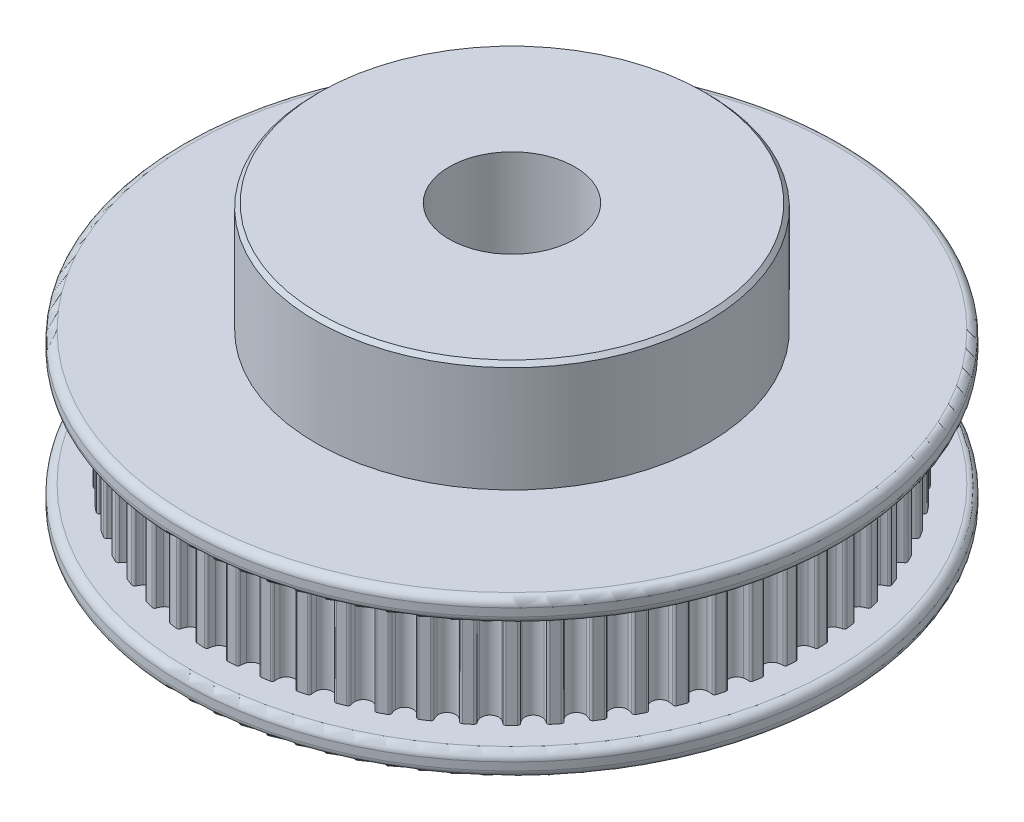
from build123d import *

# Parameters (mm, degrees)
CUT_EXTRUDE1_START = -1.5
SKETCH2_R          = 24.481100841
SKETCH2_R_2        = 4
CUT_EXTRUDE1_DEPTH = 7
FILLET1_R          = 0.5
CHAMFER1_SIZE      = 0.25


with BuildPart() as part:
    # Sketch1 → Revolve1 (revolve)
    with BuildSketch(Plane.XY):
        Polygon((4, 7.184233151), (4, 14.184233151), (12.5, 14.184233151), (12.5, 7.184233151), (21, 7.184233151), (21, -2.815766849), (4, -2.815766849), align=None)
    revolve(axis=Axis((0, -5.578947368, 0), (0, 1, 0)))

    # Sketch2 → Cut-Extrude1 (cut)
    with BuildSketch(Plane.XZ.offset(2.815766849).offset(CUT_EXTRUDE1_START)):
        with Locations((-0.003412539, -0.008889969)):
            Circle(SKETCH2_R)
        with BuildLine():
            ThreePointArc((18.830466584, -0.729534099), (18.793183335, -0.630564739), (18.699867462, -0.580794038))
            ThreePointArc((18.699867462, -0.580794038), (18.534343714, -0.551850804), (18.3760031, -0.495600717))
            ThreePointArc((18.3760031, -0.495600717), (18.152095447, -0.290974394), (18.069206646, 0.000806374))
            ThreePointArc((18.069206646, 0.000806374), (18.152095447, 0.292587141), (18.3760031, 0.497213465))
            ThreePointArc((18.3760031, 0.497213465), (18.534343714, 0.553463551), (18.699867462, 0.582406785))
            ThreePointArc((18.699867462, 0.582406785), (18.793183335, 0.632177487), (18.830466584, 0.731146846))
            ThreePointArc((18.830466584, 0.731146846), (18.818767311, 0.987862551), (18.803568396, 1.244394847))
            ThreePointArc((18.803568396, 1.244394847), (18.756144273, 1.338924881), (18.65813714, 1.378668769))
            ThreePointArc((18.65813714, 1.378668769), (18.490494756, 1.390151506), (18.327141814, 1.429542348))
            ThreePointArc((18.327141814, 1.429542348), (18.083071475, 1.609642984), (17.970137352, 1.891161107))
            ThreePointArc((17.970137352, 1.891161107), (18.022072685, 2.190007707), (18.223364473, 2.41691779))
            ThreePointArc((18.223364473, 2.41691779), (18.374957945, 2.489410833), (18.536549545, 2.535497456))
            ThreePointArc((18.536549545, 2.535497456), (18.624151769, 2.594749673), (18.650885662, 2.697074029))
            ThreePointArc((18.650885662, 2.697074029), (18.61241638, 2.951160511), (18.5704858, 3.204698777))
            ThreePointArc((18.5704858, 3.204698777), (18.513440392, 3.293753796), (18.411815784, 3.323035427))
            ThreePointArc((18.411815784, 3.323035427), (18.24389149, 3.31693186), (18.077315949, 3.339031882))
            ThreePointArc((18.077315949, 3.339031882), (17.81575701, 3.492633611), (17.674014895, 3.760804718))
            ThreePointArc((17.674014895, 3.760804718), (17.694427745, 4.063442926), (17.870898274, 4.310150692))
            ThreePointArc((17.870898274, 4.310150692), (18.014083714, 4.398092444), (18.169972734, 4.460817521))
            ThreePointArc((18.169972734, 4.460817521), (18.250901521, 4.528902074), (18.266793155, 4.63346034))
            ThreePointArc((18.266793155, 4.63346034), (18.201975343, 4.882133774), (18.133772497, 5.129900192))
            ThreePointArc((18.133772497, 5.129900192), (18.067730806, 5.212504489), (17.963602144, 5.231003049))
            ThreePointArc((17.963602144, 5.231003049), (17.797235754, 5.207380048), (17.629262649, 5.211947119))
            ThreePointArc((17.629262649, 5.211947119), (17.353080805, 5.337367048), (17.184083655, 5.589253))
            ThreePointArc((17.184083655, 5.589253), (17.172750374, 5.892367048), (17.322466195, 6.156169517))
            ThreePointArc((17.322466195, 6.156169517), (17.455674834, 6.258596468), (17.604153322, 6.337272771))
            ThreePointArc((17.604153322, 6.337272771), (17.677521998, 6.413443711), (17.682397262, 6.519090324))
            ThreePointArc((17.682397262, 6.519090324), (17.591941076, 6.759626193), (17.498213211, 6.998906182))
            ThreePointArc((17.498213211, 6.998906182), (17.423898802, 7.074154727), (17.318406942, 7.081667541))
            ThreePointArc((17.318406942, 7.081667541), (17.1554212, 7.040783927), (16.987890881, 7.027768008))
            ThreePointArc((16.987890881, 7.027768008), (16.700112037, 7.12363201), (16.50571142, 7.356473091))
            ThreePointArc((16.50571142, 7.356473091), (16.462756178, 7.656741999), (16.584076973, 7.934748895))
            ThreePointArc((16.584076973, 7.934748895), (16.70584935, 8.050538835), (16.845290544, 8.144304368))
            ThreePointArc((16.845290544, 8.144304368), (16.910295268, 8.227727152), (16.904100746, 8.333304625))
            ThreePointArc((16.904100746, 8.333304625), (16.788997244, 8.563067567), (16.67077126, 8.791239525))
            ThreePointArc((16.67077126, 8.791239525), (16.588998339, 8.85830788), (16.483299071, 8.854752636))
            ThreePointArc((16.483299071, 8.854752636), (16.325479684, 8.797056338), (16.160227647, 8.766600035))
            ThreePointArc((16.160227647, 8.766600035), (15.864004769, 8.831857803), (15.646330578, 9.043102959))
            ThreePointArc((15.646330578, 9.043102959), (15.572224002, 9.337236917), (15.663820556, 9.626402338))
            ThreePointArc((15.663820556, 9.626402338), (15.772822506, 9.754286648), (15.90169866, 9.862114098))
            ThreePointArc((15.90169866, 9.862114098), (15.957627226, 9.951874727), (15.940430787, 10.056226331))
            ThreePointArc((15.940430787, 10.056226331), (15.801941067, 10.272699016), (15.660512273, 10.487263044))
            ThreePointArc((15.660512273, 10.487263044), (15.57217676, 10.545416394), (15.467428149, 10.530832043))
            ThreePointArc((15.467428149, 10.530832043), (15.316504218, 10.456955193), (15.155340999, 10.409392192))
            ThreePointArc((15.155340999, 10.409392192), (14.853919567, 10.443328749), (14.615356687, 10.630663533))
            ThreePointArc((14.615356687, 10.630663533), (14.510910704, 10.915439948), (14.571779465, 11.212595737))
            ThreePointArc((14.571779465, 11.212595737), (14.666816741, 11.351173291), (14.78371586, 11.471881277))
            ThreePointArc((14.78371586, 11.471881277), (14.829955502, 11.566996314), (14.801945555, 11.668978752))
            ThreePointArc((14.801945555, 11.668978752), (14.641586939, 11.86978946), (14.478504858, 12.068394749))
            ThreePointArc((14.478504858, 12.068394749), (14.384574576, 12.116995953), (14.281924269, 12.091542286))
            ThreePointArc((14.281924269, 12.091542286), (14.139549348, 12.002294294), (13.984240686, 11.938145705))
            ThreePointArc((13.984240686, 11.938145705), (13.680923136, 11.940389234), (13.424085311, 12.101761168))
            ThreePointArc((13.424085311, 12.101761168), (13.290444253, 12.374059969), (13.319918331, 12.675950427))
            ThreePointArc((13.319918331, 12.675950427), (13.399949683, 12.823702938), (13.503590997, 12.955968958))
            ThreePointArc((13.503590997, 12.955968958), (13.539635105, 13.055396304), (13.501118531, 13.153892235))
            ThreePointArc((13.501118531, 13.153892235), (13.320647942, 13.336840841), (13.137699337, 13.51731143))
            ThreePointArc((13.137699337, 13.51731143), (13.039203406, 13.555828004), (12.939776059, 13.519783896))
            ThreePointArc((12.939776059, 13.519783896), (12.807510039, 13.416142582), (12.659757528, 13.336111229))
            ThreePointArc((12.659757528, 13.336111229), (12.35786707, 13.306637152), (12.085568269, 13.44027821))
            ThreePointArc((12.085568269, 13.44027821), (11.924196336, 13.697116035), (11.921952806, 14.000433585))
            ThreePointArc((11.921952806, 14.000433585), (11.986101396, 14.155742247), (12.075349387, 14.298117167))
            ThreePointArc((12.075349387, 14.298117167), (12.100803054, 14.400767475), (12.05220185, 14.494697757))
            ThreePointArc((12.05220185, 14.494697757), (11.853596561, 14.657779838), (11.652785854, 14.818138453))
            ThreePointArc((11.652785854, 14.818138453), (11.550803415, 14.846148401), (11.455688378, 14.799908759))
            ThreePointArc((11.455688378, 14.799908759), (11.334980392, 14.683009639), (11.196402839, 14.587972364))
            ThreePointArc((11.196402839, 14.587972364), (10.899247049, 14.527103602), (10.614470635, 14.631549585))
            ThreePointArc((10.614470635, 14.631549585), (10.42713585, 14.870112466), (10.393199293, 15.171533898))
            ThreePointArc((10.393199293, 15.171533898), (10.440762294, 15.332697116), (10.514639145, 15.483621048))
            ThreePointArc((10.514639145, 15.483621048), (10.529223495, 15.588369659), (10.471070145, 15.676705172))
            ThreePointArc((10.471070145, 15.676705172), (10.256506117, 15.818133966), (10.040033432, 15.956623686))
            ThreePointArc((10.040033432, 15.956623686), (9.935681828, 15.973820124), (9.845921199, 15.917891559))
            ThreePointArc((9.845921199, 15.917891559), (9.73809375, 15.789015405), (9.610209439, 15.680013455))
            ThreePointArc((9.610209439, 15.680013455), (9.321044018, 15.588416901), (9.02691006, 15.662523477))
            ThreePointArc((9.02691006, 15.662523477), (8.815664904, 15.880197668), (8.750407136, 16.176420546))
            ThreePointArc((8.750407136, 16.176420546), (8.780863439, 16.341672582), (8.838559737, 16.49949197))
            ThreePointArc((8.838559737, 16.49949197), (8.842114982, 16.605191238), (8.775046627, 16.686964159))
            ThreePointArc((8.775046627, 16.686964159), (8.546874669, 16.805190143), (8.317111726, 16.920293645))
            ThreePointArc((8.317111726, 16.920293645), (8.211534253, 16.926488167), (8.12811147, 16.861483443))
            ThreePointArc((8.12811147, 16.861483443), (8.034345936, 16.722042249), (7.918555996, 16.600269872))
            ThreePointArc((7.918555996, 16.600269872), (7.6405491, 16.478949077), (7.340280193, 16.521904318))
            ThreePointArc((7.340280193, 16.521904318), (7.107439111, 16.716304936), (7.01157511, 17.00408378))
            ThreePointArc((7.01157511, 17.00408378), (7.024591028, 17.171614099), (7.065474642, 17.334599841))
            ThreePointArc((7.065474642, 17.334599841), (7.057961828, 17.440091701), (6.982713283, 17.514406109))
            ThreePointArc((6.982713283, 17.514406109), (6.743433294, 17.608133975), (6.502897425, 17.698590161))
            ThreePointArc((6.502897425, 17.698590161), (6.397250813, 17.693714897), (6.321079872, 17.620346221))
            ThreePointArc((6.321079872, 17.620346221), (6.24240357, 17.471867733), (6.139976618, 17.338659093))
            ThreePointArc((6.139976618, 17.338659093), (5.876174149, 17.188943272), (5.573060101, 17.200276553))
            ThreePointArc((5.573060101, 17.200276553), (5.321174149, 17.369273704), (5.195754221, 17.645455548))
            ThreePointArc((5.195754221, 17.645455548), (5.19118715, 17.813428653), (5.21481015, 17.979795043))
            ThreePointArc((5.21481015, 17.979795043), (5.19631159, 18.083923705), (5.113707293, 18.149965396))
            ThreePointArc((5.113707293, 18.149965396), (4.865940876, 18.218168242), (4.617267441, 18.282986054))
            ThreePointArc((4.617267441, 18.282986054), (4.512709176, 18.26709442), (4.444624622, 18.186165633))
            ThreePointArc((4.444624622, 18.186165633), (4.381899545, 18.030276613), (4.293957793, 17.887091172))
            ThreePointArc((4.293957793, 17.887091172), (4.047250027, 17.710620644), (3.744611819, 17.690207794))
            ThreePointArc((3.744611819, 17.690207794), (3.476440712, 17.831949909), (3.322838983, 18.093508848))
            ThreePointArc((3.322838983, 18.093508848), (3.300738961, 18.260084389), (3.306842529, 18.428008683))
            ThreePointArc((3.306842529, 18.428008683), (3.277560897, 18.529633291), (3.188505878, 18.586678699))
            ThreePointArc((3.188505878, 18.586678699), (2.934967613, 18.628609279), (2.680881131, 18.66707856))
            ThreePointArc((2.680881131, 18.66707856), (2.578556775, 18.640344667), (2.519304557, 18.552742444))
            ThreePointArc((2.519304557, 18.552742444), (2.473217934, 18.391150844), (2.400724891, 18.239557372))
            ThreePointArc((2.400724891, 18.239557372), (2.173814809, 18.038265584), (1.874968208, 17.986330251))
            ThreePointArc((1.874968208, 17.986330251), (1.593450085, 18.099264374), (1.413349449, 18.343334713))
            ThreePointArc((1.413349449, 18.343334713), (1.373958607, 18.506687655), (1.362475871, 18.674330038))
            ThreePointArc((1.362475871, 18.674330038), (1.322731983, 18.772337172), (1.228201948, 18.819761295))
            ThreePointArc((1.228201948, 18.819761295), (0.971669652, 18.83496021), (0.714953948, 18.846659483))
            ThreePointArc((0.714953948, 18.846659483), (0.615984588, 18.809376233), (0.566213886, 18.716060361))
            ThreePointArc((0.566213886, 18.716060361), (0.537270652, 18.550536612), (0.481020566, 18.392195999))
            ThreePointArc((0.481020566, 18.392195999), (0.276394242, 18.168288346), (-0.015386525, 18.085399545))
            ThreePointArc((-0.015386525, 18.085399545), (-0.307167292, 18.168288346), (-0.511793616, 18.392195999))
            ThreePointArc((-0.511793616, 18.392195999), (-0.568043703, 18.550536612), (-0.596986936, 18.716060361))
            ThreePointArc((-0.596986936, 18.716060361), (-0.646757638, 18.809376233), (-0.745726998, 18.846659483))
            ThreePointArc((-0.745726998, 18.846659483), (-1.002442702, 18.83496021), (-1.258974998, 18.819761295))
            ThreePointArc((-1.258974998, 18.819761295), (-1.353505033, 18.772337172), (-1.393248921, 18.674330038))
            ThreePointArc((-1.393248921, 18.674330038), (-1.404731657, 18.506687655), (-1.444122499, 18.343334713))
            ThreePointArc((-1.444122499, 18.343334713), (-1.624223135, 18.099264374), (-1.905741258, 17.986330251))
            ThreePointArc((-1.905741258, 17.986330251), (-2.204587859, 18.038265584), (-2.431497941, 18.239557372))
            ThreePointArc((-2.431497941, 18.239557372), (-2.503990985, 18.391150844), (-2.550077607, 18.552742444))
            ThreePointArc((-2.550077607, 18.552742444), (-2.609329825, 18.640344667), (-2.711654181, 18.66707856))
            ThreePointArc((-2.711654181, 18.66707856), (-2.965740663, 18.628609279), (-3.219278929, 18.586678699))
            ThreePointArc((-3.219278929, 18.586678699), (-3.308333947, 18.529633291), (-3.337615579, 18.428008683))
            ThreePointArc((-3.337615579, 18.428008683), (-3.331512011, 18.260084389), (-3.353612034, 18.093508848))
            ThreePointArc((-3.353612034, 18.093508848), (-3.507213763, 17.831949909), (-3.775384869, 17.690207794))
            ThreePointArc((-3.775384869, 17.690207794), (-4.078023077, 17.710620644), (-4.324730844, 17.887091172))
            ThreePointArc((-4.324730844, 17.887091172), (-4.412672596, 18.030276613), (-4.475397672, 18.186165633))
            ThreePointArc((-4.475397672, 18.186165633), (-4.543482226, 18.26709442), (-4.648040491, 18.282986054))
            ThreePointArc((-4.648040491, 18.282986054), (-4.896713926, 18.218168242), (-5.144480344, 18.149965396))
            ThreePointArc((-5.144480344, 18.149965396), (-5.22708464, 18.083923705), (-5.2455832, 17.979795043))
            ThreePointArc((-5.2455832, 17.979795043), (-5.2219602, 17.813428653), (-5.226527271, 17.645455548))
            ThreePointArc((-5.226527271, 17.645455548), (-5.3519472, 17.369273704), (-5.603833151, 17.200276553))
            ThreePointArc((-5.603833151, 17.200276553), (-5.9069472, 17.188943272), (-6.170749668, 17.338659093))
            ThreePointArc((-6.170749668, 17.338659093), (-6.27317662, 17.471867733), (-6.351852922, 17.620346221))
            ThreePointArc((-6.351852922, 17.620346221), (-6.428023863, 17.693714897), (-6.533670475, 17.698590161))
            ThreePointArc((-6.533670475, 17.698590161), (-6.774206344, 17.608133975), (-7.013486333, 17.514406109))
            ThreePointArc((-7.013486333, 17.514406109), (-7.088734879, 17.440091701), (-7.096247692, 17.334599841))
            ThreePointArc((-7.096247692, 17.334599841), (-7.055364078, 17.171614099), (-7.04234816, 17.00408378))
            ThreePointArc((-7.04234816, 17.00408378), (-7.138212161, 16.716304936), (-7.371053243, 16.521904318))
            ThreePointArc((-7.371053243, 16.521904318), (-7.67132215, 16.478949077), (-7.949329046, 16.600269872))
            ThreePointArc((-7.949329046, 16.600269872), (-8.065118987, 16.722042249), (-8.15888452, 16.861483443))
            ThreePointArc((-8.15888452, 16.861483443), (-8.242307303, 16.926488167), (-8.347884776, 16.920293645))
            ThreePointArc((-8.347884776, 16.920293645), (-8.577647719, 16.805190143), (-8.805819677, 16.686964159))
            ThreePointArc((-8.805819677, 16.686964159), (-8.872888032, 16.605191238), (-8.869332788, 16.49949197))
            ThreePointArc((-8.869332788, 16.49949197), (-8.811636489, 16.341672582), (-8.781180186, 16.176420546))
            ThreePointArc((-8.781180186, 16.176420546), (-8.846437955, 15.880197668), (-9.057683111, 15.662523477))
            ThreePointArc((-9.057683111, 15.662523477), (-9.351817068, 15.588416901), (-9.640982489, 15.680013455))
            ThreePointArc((-9.640982489, 15.680013455), (-9.7688668, 15.789015405), (-9.87669425, 15.917891559))
            ThreePointArc((-9.87669425, 15.917891559), (-9.966454878, 15.973820124), (-10.070806483, 15.956623686))
            ThreePointArc((-10.070806483, 15.956623686), (-10.287279168, 15.818133966), (-10.501843195, 15.676705172))
            ThreePointArc((-10.501843195, 15.676705172), (-10.559996545, 15.588369659), (-10.545412195, 15.483621048))
            ThreePointArc((-10.545412195, 15.483621048), (-10.471535345, 15.332697116), (-10.423972343, 15.171533898))
            ThreePointArc((-10.423972343, 15.171533898), (-10.4579089, 14.870112466), (-10.645243685, 14.631549585))
            ThreePointArc((-10.645243685, 14.631549585), (-10.930020099, 14.527103602), (-11.227175889, 14.587972364))
            ThreePointArc((-11.227175889, 14.587972364), (-11.365753442, 14.683009639), (-11.486461428, 14.799908759))
            ThreePointArc((-11.486461428, 14.799908759), (-11.581576466, 14.846148401), (-11.683558904, 14.818138453))
            ThreePointArc((-11.683558904, 14.818138453), (-11.884369611, 14.657779838), (-12.0829749, 14.494697757))
            ThreePointArc((-12.0829749, 14.494697757), (-12.131576104, 14.400767475), (-12.106122438, 14.298117167))
            ThreePointArc((-12.106122438, 14.298117167), (-12.016874446, 14.155742247), (-11.952725856, 14.000433585))
            ThreePointArc((-11.952725856, 14.000433585), (-11.954969386, 13.697116035), (-12.116341319, 13.44027821))
            ThreePointArc((-12.116341319, 13.44027821), (-12.388640121, 13.306637152), (-12.690530578, 13.336111229))
            ThreePointArc((-12.690530578, 13.336111229), (-12.838283089, 13.416142582), (-12.97054911, 13.519783896))
            ThreePointArc((-12.97054911, 13.519783896), (-13.069976456, 13.555828004), (-13.168472387, 13.51731143))
            ThreePointArc((-13.168472387, 13.51731143), (-13.351420992, 13.336840841), (-13.531891582, 13.153892235))
            ThreePointArc((-13.531891582, 13.153892235), (-13.570408155, 13.055396304), (-13.534364047, 12.955968958))
            ThreePointArc((-13.534364047, 12.955968958), (-13.430722734, 12.823702938), (-13.350691381, 12.675950427))
            ThreePointArc((-13.350691381, 12.675950427), (-13.321217303, 12.374059969), (-13.454858361, 12.101761168))
            ThreePointArc((-13.454858361, 12.101761168), (-13.711696187, 11.940389234), (-14.015013736, 11.938145705))
            ThreePointArc((-14.015013736, 11.938145705), (-14.170322398, 12.002294294), (-14.312697319, 12.091542286))
            ThreePointArc((-14.312697319, 12.091542286), (-14.415347627, 12.116995953), (-14.509277909, 12.068394749))
            ThreePointArc((-14.509277909, 12.068394749), (-14.672359989, 11.86978946), (-14.832718605, 11.668978752))
            ThreePointArc((-14.832718605, 11.668978752), (-14.860728553, 11.566996314), (-14.81448891, 11.471881277))
            ThreePointArc((-14.81448891, 11.471881277), (-14.697589791, 11.351173291), (-14.602552515, 11.212595737))
            ThreePointArc((-14.602552515, 11.212595737), (-14.541683754, 10.915439948), (-14.646129737, 10.630663533))
            ThreePointArc((-14.646129737, 10.630663533), (-14.884692618, 10.443328749), (-15.18611405, 10.409392192))
            ThreePointArc((-15.18611405, 10.409392192), (-15.347277268, 10.456955193), (-15.498201199, 10.530832043))
            ThreePointArc((-15.498201199, 10.530832043), (-15.602949811, 10.545416394), (-15.691285323, 10.487263044))
            ThreePointArc((-15.691285323, 10.487263044), (-15.832714117, 10.272699016), (-15.971203837, 10.056226331))
            ThreePointArc((-15.971203837, 10.056226331), (-15.988400276, 9.951874727), (-15.932471711, 9.862114098))
            ThreePointArc((-15.932471711, 9.862114098), (-15.803595556, 9.754286648), (-15.694593606, 9.626402338))
            ThreePointArc((-15.694593606, 9.626402338), (-15.602997052, 9.337236917), (-15.677103628, 9.043102959))
            ThreePointArc((-15.677103628, 9.043102959), (-15.89477782, 8.831857803), (-16.191000697, 8.766600035))
            ThreePointArc((-16.191000697, 8.766600035), (-16.356252734, 8.797056338), (-16.514072122, 8.854752636))
            ThreePointArc((-16.514072122, 8.854752636), (-16.619771389, 8.85830788), (-16.70154431, 8.791239525))
            ThreePointArc((-16.70154431, 8.791239525), (-16.819770295, 8.563067567), (-16.934873796, 8.333304625))
            ThreePointArc((-16.934873796, 8.333304625), (-16.941068318, 8.227727152), (-16.876063595, 8.144304368))
            ThreePointArc((-16.876063595, 8.144304368), (-16.7366224, 8.050538835), (-16.614850023, 7.934748895))
            ThreePointArc((-16.614850023, 7.934748895), (-16.493529228, 7.656741999), (-16.53648447, 7.356473091))
            ThreePointArc((-16.53648447, 7.356473091), (-16.730885088, 7.12363201), (-17.018663931, 7.027768008))
            ThreePointArc((-17.018663931, 7.027768008), (-17.18619425, 7.040783927), (-17.349179992, 7.081667541))
            ThreePointArc((-17.349179992, 7.081667541), (-17.454671852, 7.074154727), (-17.528986261, 6.998906182))
            ThreePointArc((-17.528986261, 6.998906182), (-17.622714127, 6.759626193), (-17.713170312, 6.519090324))
            ThreePointArc((-17.713170312, 6.519090324), (-17.708295049, 6.413443711), (-17.634926373, 6.337272771))
            ThreePointArc((-17.634926373, 6.337272771), (-17.486447884, 6.258596468), (-17.353239245, 6.156169517))
            ThreePointArc((-17.353239245, 6.156169517), (-17.203523424, 5.892367048), (-17.214856705, 5.589253))
            ThreePointArc((-17.214856705, 5.589253), (-17.383853855, 5.337367048), (-17.660035699, 5.211947119))
            ThreePointArc((-17.660035699, 5.211947119), (-17.828008804, 5.207380048), (-17.994375195, 5.231003049))
            ThreePointArc((-17.994375195, 5.231003049), (-18.098503856, 5.212504489), (-18.164545548, 5.129900192))
            ThreePointArc((-18.164545548, 5.129900192), (-18.232748393, 4.882133774), (-18.297566205, 4.63346034))
            ThreePointArc((-18.297566205, 4.63346034), (-18.281674571, 4.528902074), (-18.200745785, 4.460817521))
            ThreePointArc((-18.200745785, 4.460817521), (-18.044856764, 4.398092444), (-17.901671324, 4.310150692))
            ThreePointArc((-17.901671324, 4.310150692), (-17.725200795, 4.063442926), (-17.704787946, 3.760804718))
            ThreePointArc((-17.704787946, 3.760804718), (-17.84653006, 3.492633611), (-18.108088999, 3.339031882))
            ThreePointArc((-18.108088999, 3.339031882), (-18.274664541, 3.31693186), (-18.442588834, 3.323035427))
            ThreePointArc((-18.442588834, 3.323035427), (-18.544213442, 3.293753796), (-18.60125885, 3.204698777))
            ThreePointArc((-18.60125885, 3.204698777), (-18.643189431, 2.951160511), (-18.681658712, 2.697074029))
            ThreePointArc((-18.681658712, 2.697074029), (-18.654924819, 2.594749673), (-18.567322595, 2.535497456))
            ThreePointArc((-18.567322595, 2.535497456), (-18.405730995, 2.489410833), (-18.254137524, 2.41691779))
            ThreePointArc((-18.254137524, 2.41691779), (-18.052845735, 2.190007707), (-18.000910403, 1.891161107))
            ThreePointArc((-18.000910403, 1.891161107), (-18.113844526, 1.609642984), (-18.357914864, 1.429542348))
            ThreePointArc((-18.357914864, 1.429542348), (-18.521267806, 1.390151506), (-18.68891019, 1.378668769))
            ThreePointArc((-18.68891019, 1.378668769), (-18.786917323, 1.338924881), (-18.834341447, 1.244394847))
            ThreePointArc((-18.834341447, 1.244394847), (-18.849540361, 0.987862551), (-18.861239634, 0.731146846))
            ThreePointArc((-18.861239634, 0.731146846), (-18.823956385, 0.632177487), (-18.730640512, 0.582406785))
            ThreePointArc((-18.730640512, 0.582406785), (-18.565116764, 0.553463551), (-18.406776151, 0.497213465))
            ThreePointArc((-18.406776151, 0.497213465), (-18.182868498, 0.292587141), (-18.099979696, 0.000806374))
            ThreePointArc((-18.099979696, 0.000806374), (-18.182868498, -0.290974394), (-18.406776151, -0.495600717))
            ThreePointArc((-18.406776151, -0.495600717), (-18.565116764, -0.551850804), (-18.730640512, -0.580794038))
            ThreePointArc((-18.730640512, -0.580794038), (-18.823956385, -0.630564739), (-18.861239634, -0.729534099))
            ThreePointArc((-18.861239634, -0.729534099), (-18.849540361, -0.986249804), (-18.834341447, -1.2427821))
            ThreePointArc((-18.834341447, -1.2427821), (-18.786917323, -1.337312134), (-18.68891019, -1.377056022))
            ThreePointArc((-18.68891019, -1.377056022), (-18.521267806, -1.388538759), (-18.357914864, -1.4279296))
            ThreePointArc((-18.357914864, -1.4279296), (-18.113844526, -1.608030237), (-18.000910403, -1.889548359))
            ThreePointArc((-18.000910403, -1.889548359), (-18.052845735, -2.18839496), (-18.254137524, -2.415305042))
            ThreePointArc((-18.254137524, -2.415305042), (-18.405730995, -2.487798086), (-18.567322595, -2.533884709))
            ThreePointArc((-18.567322595, -2.533884709), (-18.654924819, -2.593136926), (-18.681658712, -2.695461282))
            ThreePointArc((-18.681658712, -2.695461282), (-18.643189431, -2.949547764), (-18.60125885, -3.20308603))
            ThreePointArc((-18.60125885, -3.20308603), (-18.544213442, -3.292141048), (-18.442588834, -3.32142268))
            ThreePointArc((-18.442588834, -3.32142268), (-18.274664541, -3.315319112), (-18.108088999, -3.337419135))
            ThreePointArc((-18.108088999, -3.337419135), (-17.84653006, -3.491020864), (-17.704787946, -3.75919197))
            ThreePointArc((-17.704787946, -3.75919197), (-17.725200795, -4.061830179), (-17.901671324, -4.308537945))
            ThreePointArc((-17.901671324, -4.308537945), (-18.044856764, -4.396479697), (-18.200745785, -4.459204774))
            ThreePointArc((-18.200745785, -4.459204774), (-18.281674571, -4.527289327), (-18.297566205, -4.631847593))
            ThreePointArc((-18.297566205, -4.631847593), (-18.232748393, -4.880521027), (-18.164545548, -5.128287445))
            ThreePointArc((-18.164545548, -5.128287445), (-18.098503856, -5.210891742), (-17.994375195, -5.229390301))
            ThreePointArc((-17.994375195, -5.229390301), (-17.828008804, -5.205767301), (-17.660035699, -5.210334372))
            ThreePointArc((-17.660035699, -5.210334372), (-17.383853855, -5.335754301), (-17.214856705, -5.587640253))
            ThreePointArc((-17.214856705, -5.587640253), (-17.203523424, -5.890754301), (-17.353239245, -6.154556769))
            ThreePointArc((-17.353239245, -6.154556769), (-17.486447884, -6.256983721), (-17.634926373, -6.335660023))
            ThreePointArc((-17.634926373, -6.335660023), (-17.708295049, -6.411830964), (-17.713170312, -6.517477577))
            ThreePointArc((-17.713170312, -6.517477577), (-17.622714127, -6.758013446), (-17.528986261, -6.997293434))
            ThreePointArc((-17.528986261, -6.997293434), (-17.454671852, -7.07254198), (-17.349179992, -7.080054794))
            ThreePointArc((-17.349179992, -7.080054794), (-17.18619425, -7.039171179), (-17.018663931, -7.026155261))
            ThreePointArc((-17.018663931, -7.026155261), (-16.730885088, -7.122019262), (-16.53648447, -7.354860344))
            ThreePointArc((-16.53648447, -7.354860344), (-16.493529228, -7.655129252), (-16.614850023, -7.933136147))
            ThreePointArc((-16.614850023, -7.933136147), (-16.7366224, -8.048926088), (-16.876063595, -8.142691621))
            ThreePointArc((-16.876063595, -8.142691621), (-16.941068318, -8.226114405), (-16.934873796, -8.331691878))
            ThreePointArc((-16.934873796, -8.331691878), (-16.819770295, -8.56145482), (-16.70154431, -8.789626778))
            ThreePointArc((-16.70154431, -8.789626778), (-16.619771389, -8.856695133), (-16.514072122, -8.853139889))
            ThreePointArc((-16.514072122, -8.853139889), (-16.356252734, -8.79544359), (-16.191000697, -8.764987288))
            ThreePointArc((-16.191000697, -8.764987288), (-15.89477782, -8.830245056), (-15.677103628, -9.041490212))
            ThreePointArc((-15.677103628, -9.041490212), (-15.602997052, -9.335624169), (-15.694593606, -9.624789591))
            ThreePointArc((-15.694593606, -9.624789591), (-15.803595556, -9.752673901), (-15.932471711, -9.860501351))
            ThreePointArc((-15.932471711, -9.860501351), (-15.988400276, -9.950261979), (-15.971203837, -10.054613584))
            ThreePointArc((-15.971203837, -10.054613584), (-15.832714117, -10.271086269), (-15.691285323, -10.485650297))
            ThreePointArc((-15.691285323, -10.485650297), (-15.602949811, -10.543803646), (-15.498201199, -10.529219296))
            ThreePointArc((-15.498201199, -10.529219296), (-15.347277268, -10.455342446), (-15.18611405, -10.407779445))
            ThreePointArc((-15.18611405, -10.407779445), (-14.884692618, -10.441716002), (-14.646129737, -10.629050786))
            ThreePointArc((-14.646129737, -10.629050786), (-14.541683754, -10.9138272), (-14.602552515, -11.21098299))
            ThreePointArc((-14.602552515, -11.21098299), (-14.697589791, -11.349560543), (-14.81448891, -11.470268529))
            ThreePointArc((-14.81448891, -11.470268529), (-14.860728553, -11.565383567), (-14.832718605, -11.667366005))
            ThreePointArc((-14.832718605, -11.667366005), (-14.672359989, -11.868176712), (-14.509277909, -12.066782002))
            ThreePointArc((-14.509277909, -12.066782002), (-14.415347627, -12.115383206), (-14.312697319, -12.089929539))
            ThreePointArc((-14.312697319, -12.089929539), (-14.170322398, -12.000681547), (-14.015013736, -11.936532957))
            ThreePointArc((-14.015013736, -11.936532957), (-13.711696187, -11.938776487), (-13.454858361, -12.100148421))
            ThreePointArc((-13.454858361, -12.100148421), (-13.321217303, -12.372447222), (-13.350691381, -12.674337679))
            ThreePointArc((-13.350691381, -12.674337679), (-13.430722734, -12.822090191), (-13.534364047, -12.954356211))
            ThreePointArc((-13.534364047, -12.954356211), (-13.570408155, -13.053783557), (-13.531891582, -13.152279488))
            ThreePointArc((-13.531891582, -13.152279488), (-13.351420992, -13.335228094), (-13.168472387, -13.515698683))
            ThreePointArc((-13.168472387, -13.515698683), (-13.069976456, -13.554215257), (-12.97054911, -13.518171148))
            ThreePointArc((-12.97054911, -13.518171148), (-12.838283089, -13.414529835), (-12.690530578, -13.334498482))
            ThreePointArc((-12.690530578, -13.334498482), (-12.388640121, -13.305024404), (-12.116341319, -13.438665462))
            ThreePointArc((-12.116341319, -13.438665462), (-11.954969386, -13.695503288), (-11.952725856, -13.998820838))
            ThreePointArc((-11.952725856, -13.998820838), (-12.016874446, -14.1541295), (-12.106122438, -14.29650442))
            ThreePointArc((-12.106122438, -14.29650442), (-12.131576104, -14.399154728), (-12.0829749, -14.49308501))
            ThreePointArc((-12.0829749, -14.49308501), (-11.884369611, -14.65616709), (-11.683558904, -14.816525706))
            ThreePointArc((-11.683558904, -14.816525706), (-11.581576466, -14.844535654), (-11.486461428, -14.798296011))
            ThreePointArc((-11.486461428, -14.798296011), (-11.365753442, -14.681396892), (-11.227175889, -14.586359616))
            ThreePointArc((-11.227175889, -14.586359616), (-10.930020099, -14.525490855), (-10.645243685, -14.629936838))
            ThreePointArc((-10.645243685, -14.629936838), (-10.4579089, -14.868499719), (-10.423972343, -15.169921151))
            ThreePointArc((-10.423972343, -15.169921151), (-10.471535345, -15.331084369), (-10.545412195, -15.4820083))
            ThreePointArc((-10.545412195, -15.4820083), (-10.559996545, -15.586756912), (-10.501843195, -15.675092424))
            ThreePointArc((-10.501843195, -15.675092424), (-10.287279168, -15.816521219), (-10.070806483, -15.955010939))
            ThreePointArc((-10.070806483, -15.955010939), (-9.966454878, -15.972207377), (-9.87669425, -15.916278812))
            ThreePointArc((-9.87669425, -15.916278812), (-9.7688668, -15.787402658), (-9.640982489, -15.678400707))
            ThreePointArc((-9.640982489, -15.678400707), (-9.351817068, -15.586804154), (-9.057683111, -15.66091073))
            ThreePointArc((-9.057683111, -15.66091073), (-8.846437955, -15.878584921), (-8.781180186, -16.174807798))
            ThreePointArc((-8.781180186, -16.174807798), (-8.811636489, -16.340059835), (-8.869332788, -16.497879223))
            ThreePointArc((-8.869332788, -16.497879223), (-8.872888032, -16.60357849), (-8.805819677, -16.685351412))
            ThreePointArc((-8.805819677, -16.685351412), (-8.577647719, -16.803577396), (-8.347884776, -16.918680898))
            ThreePointArc((-8.347884776, -16.918680898), (-8.242307303, -16.924875419), (-8.15888452, -16.859870696))
            ThreePointArc((-8.15888452, -16.859870696), (-8.065118987, -16.720429501), (-7.949329046, -16.598657125))
            ThreePointArc((-7.949329046, -16.598657125), (-7.67132215, -16.477336329), (-7.371053243, -16.520291571))
            ThreePointArc((-7.371053243, -16.520291571), (-7.138212161, -16.714692189), (-7.04234816, -17.002471032))
            ThreePointArc((-7.04234816, -17.002471032), (-7.055364078, -17.170001352), (-7.096247692, -17.332987094))
            ThreePointArc((-7.096247692, -17.332987094), (-7.088734879, -17.438478954), (-7.013486333, -17.512793362))
            ThreePointArc((-7.013486333, -17.512793362), (-6.774206344, -17.606521228), (-6.533670475, -17.696977413))
            ThreePointArc((-6.533670475, -17.696977413), (-6.428023863, -17.69210215), (-6.351852922, -17.618733474))
            ThreePointArc((-6.351852922, -17.618733474), (-6.27317662, -17.470254985), (-6.170749668, -17.337046346))
            ThreePointArc((-6.170749668, -17.337046346), (-5.9069472, -17.187330525), (-5.603833151, -17.198663806))
            ThreePointArc((-5.603833151, -17.198663806), (-5.3519472, -17.367660957), (-5.226527271, -17.643842801))
            ThreePointArc((-5.226527271, -17.643842801), (-5.2219602, -17.811815905), (-5.2455832, -17.978182296))
            ThreePointArc((-5.2455832, -17.978182296), (-5.22708464, -18.082310957), (-5.144480344, -18.148352649))
            ThreePointArc((-5.144480344, -18.148352649), (-4.896713926, -18.216555494), (-4.648040491, -18.281373306))
            ThreePointArc((-4.648040491, -18.281373306), (-4.543482226, -18.265481672), (-4.475397672, -18.184552886))
            ThreePointArc((-4.475397672, -18.184552886), (-4.412672596, -18.028663865), (-4.324730844, -17.885478425))
            ThreePointArc((-4.324730844, -17.885478425), (-4.078023077, -17.709007896), (-3.775384869, -17.688595047))
            ThreePointArc((-3.775384869, -17.688595047), (-3.507213763, -17.830337162), (-3.353612034, -18.0918961))
            ThreePointArc((-3.353612034, -18.0918961), (-3.331512011, -18.258471642), (-3.337615579, -18.426395936))
            ThreePointArc((-3.337615579, -18.426395936), (-3.308333947, -18.528020544), (-3.219278929, -18.585065952))
            ThreePointArc((-3.219278929, -18.585065952), (-2.965740663, -18.626996532), (-2.711654181, -18.665465813))
            ThreePointArc((-2.711654181, -18.665465813), (-2.609329825, -18.63873192), (-2.550077607, -18.551129697))
            ThreePointArc((-2.550077607, -18.551129697), (-2.503990985, -18.389538096), (-2.431497941, -18.237944625))
            ThreePointArc((-2.431497941, -18.237944625), (-2.204587859, -18.036652836), (-1.905741258, -17.984717504))
            ThreePointArc((-1.905741258, -17.984717504), (-1.624223135, -18.097651627), (-1.444122499, -18.341721966))
            ThreePointArc((-1.444122499, -18.341721966), (-1.404731657, -18.505074907), (-1.393248921, -18.672717291))
            ThreePointArc((-1.393248921, -18.672717291), (-1.353505033, -18.770724425), (-1.258974998, -18.818148548))
            ThreePointArc((-1.258974998, -18.818148548), (-1.002442702, -18.833347463), (-0.745726998, -18.845046736))
            ThreePointArc((-0.745726998, -18.845046736), (-0.646757638, -18.807763486), (-0.596986936, -18.714447613))
            ThreePointArc((-0.596986936, -18.714447613), (-0.568043703, -18.548923865), (-0.511793616, -18.390583252))
            ThreePointArc((-0.511793616, -18.390583252), (-0.307167292, -18.166675599), (-0.015386525, -18.083786797))
            ThreePointArc((-0.015386525, -18.083786797), (0.276394242, -18.166675599), (0.481020566, -18.390583252))
            ThreePointArc((0.481020566, -18.390583252), (0.537270652, -18.548923865), (0.566213886, -18.714447613))
            ThreePointArc((0.566213886, -18.714447613), (0.615984588, -18.807763486), (0.714953948, -18.845046736))
            ThreePointArc((0.714953948, -18.845046736), (0.971669652, -18.833347463), (1.228201948, -18.818148548))
            ThreePointArc((1.228201948, -18.818148548), (1.322731983, -18.770724425), (1.362475871, -18.672717291))
            ThreePointArc((1.362475871, -18.672717291), (1.373958607, -18.505074907), (1.413349449, -18.341721966))
            ThreePointArc((1.413349449, -18.341721966), (1.593450085, -18.097651627), (1.874968208, -17.984717504))
            ThreePointArc((1.874968208, -17.984717504), (2.173814809, -18.036652836), (2.400724891, -18.237944625))
            ThreePointArc((2.400724891, -18.237944625), (2.473217934, -18.389538096), (2.519304557, -18.551129697))
            ThreePointArc((2.519304557, -18.551129697), (2.578556775, -18.63873192), (2.680881131, -18.665465813))
            ThreePointArc((2.680881131, -18.665465813), (2.934967613, -18.626996532), (3.188505878, -18.585065952))
            ThreePointArc((3.188505878, -18.585065952), (3.277560897, -18.528020544), (3.306842529, -18.426395936))
            ThreePointArc((3.306842529, -18.426395936), (3.300738961, -18.258471642), (3.322838983, -18.0918961))
            ThreePointArc((3.322838983, -18.0918961), (3.476440712, -17.830337162), (3.744611819, -17.688595047))
            ThreePointArc((3.744611819, -17.688595047), (4.047250027, -17.709007896), (4.293957793, -17.885478425))
            ThreePointArc((4.293957793, -17.885478425), (4.381899545, -18.028663865), (4.444624622, -18.184552886))
            ThreePointArc((4.444624622, -18.184552886), (4.512709176, -18.265481672), (4.617267441, -18.281373306))
            ThreePointArc((4.617267441, -18.281373306), (4.865940876, -18.216555494), (5.113707293, -18.148352649))
            ThreePointArc((5.113707293, -18.148352649), (5.19631159, -18.082310957), (5.21481015, -17.978182296))
            ThreePointArc((5.21481015, -17.978182296), (5.19118715, -17.811815905), (5.195754221, -17.643842801))
            ThreePointArc((5.195754221, -17.643842801), (5.321174149, -17.367660957), (5.573060101, -17.198663806))
            ThreePointArc((5.573060101, -17.198663806), (5.876174149, -17.187330525), (6.139976618, -17.337046346))
            ThreePointArc((6.139976618, -17.337046346), (6.24240357, -17.470254985), (6.321079872, -17.618733474))
            ThreePointArc((6.321079872, -17.618733474), (6.397250813, -17.69210215), (6.502897425, -17.696977413))
            ThreePointArc((6.502897425, -17.696977413), (6.743433294, -17.606521228), (6.982713283, -17.512793362))
            ThreePointArc((6.982713283, -17.512793362), (7.057961828, -17.438478954), (7.065474642, -17.332987094))
            ThreePointArc((7.065474642, -17.332987094), (7.024591028, -17.170001352), (7.01157511, -17.002471032))
            ThreePointArc((7.01157511, -17.002471032), (7.107439111, -16.714692189), (7.340280193, -16.520291571))
            ThreePointArc((7.340280193, -16.520291571), (7.6405491, -16.477336329), (7.918555996, -16.598657125))
            ThreePointArc((7.918555996, -16.598657125), (8.034345936, -16.720429501), (8.12811147, -16.859870696))
            ThreePointArc((8.12811147, -16.859870696), (8.211534253, -16.924875419), (8.317111726, -16.918680898))
            ThreePointArc((8.317111726, -16.918680898), (8.546874669, -16.803577396), (8.775046627, -16.685351412))
            ThreePointArc((8.775046627, -16.685351412), (8.842114982, -16.60357849), (8.838559737, -16.497879223))
            ThreePointArc((8.838559737, -16.497879223), (8.780863439, -16.340059835), (8.750407136, -16.174807798))
            ThreePointArc((8.750407136, -16.174807798), (8.815664904, -15.878584921), (9.02691006, -15.66091073))
            ThreePointArc((9.02691006, -15.66091073), (9.321044018, -15.586804154), (9.610209439, -15.678400707))
            ThreePointArc((9.610209439, -15.678400707), (9.73809375, -15.787402658), (9.845921199, -15.916278812))
            ThreePointArc((9.845921199, -15.916278812), (9.935681828, -15.972207377), (10.040033432, -15.955010939))
            ThreePointArc((10.040033432, -15.955010939), (10.256506117, -15.816521219), (10.471070145, -15.675092424))
            ThreePointArc((10.471070145, -15.675092424), (10.529223495, -15.586756912), (10.514639145, -15.4820083))
            ThreePointArc((10.514639145, -15.4820083), (10.440762294, -15.331084369), (10.393199293, -15.169921151))
            ThreePointArc((10.393199293, -15.169921151), (10.42713585, -14.868499719), (10.614470635, -14.629936838))
            ThreePointArc((10.614470635, -14.629936838), (10.899247049, -14.525490855), (11.196402839, -14.586359616))
            ThreePointArc((11.196402839, -14.586359616), (11.334980392, -14.681396892), (11.455688378, -14.798296011))
            ThreePointArc((11.455688378, -14.798296011), (11.550803415, -14.844535654), (11.652785854, -14.816525706))
            ThreePointArc((11.652785854, -14.816525706), (11.853596561, -14.65616709), (12.05220185, -14.49308501))
            ThreePointArc((12.05220185, -14.49308501), (12.100803054, -14.399154728), (12.075349387, -14.29650442))
            ThreePointArc((12.075349387, -14.29650442), (11.986101396, -14.1541295), (11.921952806, -13.998820838))
            ThreePointArc((11.921952806, -13.998820838), (11.924196336, -13.695503288), (12.085568269, -13.438665462))
            ThreePointArc((12.085568269, -13.438665462), (12.35786707, -13.305024404), (12.659757528, -13.334498482))
            ThreePointArc((12.659757528, -13.334498482), (12.807510039, -13.414529835), (12.939776059, -13.518171148))
            ThreePointArc((12.939776059, -13.518171148), (13.039203406, -13.554215257), (13.137699337, -13.515698683))
            ThreePointArc((13.137699337, -13.515698683), (13.320647942, -13.335228094), (13.501118531, -13.152279488))
            ThreePointArc((13.501118531, -13.152279488), (13.539635105, -13.053783557), (13.503590997, -12.954356211))
            ThreePointArc((13.503590997, -12.954356211), (13.399949683, -12.822090191), (13.319918331, -12.674337679))
            ThreePointArc((13.319918331, -12.674337679), (13.290444253, -12.372447222), (13.424085311, -12.100148421))
            ThreePointArc((13.424085311, -12.100148421), (13.680923136, -11.938776487), (13.984240686, -11.936532957))
            ThreePointArc((13.984240686, -11.936532957), (14.139549348, -12.000681547), (14.281924269, -12.089929539))
            ThreePointArc((14.281924269, -12.089929539), (14.384574576, -12.115383206), (14.478504858, -12.066782002))
            ThreePointArc((14.478504858, -12.066782002), (14.641586939, -11.868176712), (14.801945555, -11.667366005))
            ThreePointArc((14.801945555, -11.667366005), (14.829955502, -11.565383567), (14.78371586, -11.470268529))
            ThreePointArc((14.78371586, -11.470268529), (14.666816741, -11.349560543), (14.571779465, -11.21098299))
            ThreePointArc((14.571779465, -11.21098299), (14.510910704, -10.9138272), (14.615356687, -10.629050786))
            ThreePointArc((14.615356687, -10.629050786), (14.853919567, -10.441716002), (15.155340999, -10.407779445))
            ThreePointArc((15.155340999, -10.407779445), (15.316504218, -10.455342446), (15.467428149, -10.529219296))
            ThreePointArc((15.467428149, -10.529219296), (15.57217676, -10.543803646), (15.660512273, -10.485650297))
            ThreePointArc((15.660512273, -10.485650297), (15.801941067, -10.271086269), (15.940430787, -10.054613584))
            ThreePointArc((15.940430787, -10.054613584), (15.957627226, -9.950261979), (15.90169866, -9.860501351))
            ThreePointArc((15.90169866, -9.860501351), (15.772822506, -9.752673901), (15.663820556, -9.624789591))
            ThreePointArc((15.663820556, -9.624789591), (15.572224002, -9.335624169), (15.646330578, -9.041490212))
            ThreePointArc((15.646330578, -9.041490212), (15.864004769, -8.830245056), (16.160227647, -8.764987288))
            ThreePointArc((16.160227647, -8.764987288), (16.325479684, -8.79544359), (16.483299071, -8.853139889))
            ThreePointArc((16.483299071, -8.853139889), (16.588998339, -8.856695133), (16.67077126, -8.789626778))
            ThreePointArc((16.67077126, -8.789626778), (16.788997244, -8.56145482), (16.904100746, -8.331691878))
            ThreePointArc((16.904100746, -8.331691878), (16.910295268, -8.226114405), (16.845290544, -8.142691621))
            ThreePointArc((16.845290544, -8.142691621), (16.70584935, -8.048926088), (16.584076973, -7.933136147))
            ThreePointArc((16.584076973, -7.933136147), (16.462756178, -7.655129252), (16.50571142, -7.354860344))
            ThreePointArc((16.50571142, -7.354860344), (16.700112037, -7.122019262), (16.987890881, -7.026155261))
            ThreePointArc((16.987890881, -7.026155261), (17.1554212, -7.039171179), (17.318406942, -7.080054794))
            ThreePointArc((17.318406942, -7.080054794), (17.423898802, -7.07254198), (17.498213211, -6.997293434))
            ThreePointArc((17.498213211, -6.997293434), (17.591941076, -6.758013446), (17.682397262, -6.517477577))
            ThreePointArc((17.682397262, -6.517477577), (17.677521998, -6.411830964), (17.604153322, -6.335660023))
            ThreePointArc((17.604153322, -6.335660023), (17.455674834, -6.256983721), (17.322466195, -6.154556769))
            ThreePointArc((17.322466195, -6.154556769), (17.172750374, -5.890754301), (17.184083655, -5.587640253))
            ThreePointArc((17.184083655, -5.587640253), (17.353080805, -5.335754301), (17.629262649, -5.210334372))
            ThreePointArc((17.629262649, -5.210334372), (17.797235754, -5.205767301), (17.963602144, -5.229390301))
            ThreePointArc((17.963602144, -5.229390301), (18.067730806, -5.210891742), (18.133772497, -5.128287445))
            ThreePointArc((18.133772497, -5.128287445), (18.201975343, -4.880521027), (18.266793155, -4.631847593))
            ThreePointArc((18.266793155, -4.631847593), (18.250901521, -4.527289327), (18.169972734, -4.459204774))
            ThreePointArc((18.169972734, -4.459204774), (18.014083714, -4.396479697), (17.870898274, -4.308537945))
            ThreePointArc((17.870898274, -4.308537945), (17.694427745, -4.061830179), (17.674014895, -3.75919197))
            ThreePointArc((17.674014895, -3.75919197), (17.81575701, -3.491020864), (18.077315949, -3.337419135))
            ThreePointArc((18.077315949, -3.337419135), (18.24389149, -3.315319112), (18.411815784, -3.32142268))
            ThreePointArc((18.411815784, -3.32142268), (18.513440392, -3.292141048), (18.5704858, -3.20308603))
            ThreePointArc((18.5704858, -3.20308603), (18.61241638, -2.949547764), (18.650885662, -2.695461282))
            ThreePointArc((18.650885662, -2.695461282), (18.624151769, -2.593136926), (18.536549545, -2.533884709))
            ThreePointArc((18.536549545, -2.533884709), (18.374957945, -2.487798086), (18.223364473, -2.415305042))
            ThreePointArc((18.223364473, -2.415305042), (18.022072685, -2.18839496), (17.970137352, -1.889548359))
            ThreePointArc((17.970137352, -1.889548359), (18.083071475, -1.608030237), (18.327141814, -1.4279296))
            ThreePointArc((18.327141814, -1.4279296), (18.490494756, -1.388538759), (18.65813714, -1.377056022))
            ThreePointArc((18.65813714, -1.377056022), (18.756144273, -1.337312134), (18.803568396, -1.2427821))
            ThreePointArc((18.803568396, -1.2427821), (18.818767311, -0.986249804), (18.830466584, -0.729534099))
        make_face(mode=Mode.SUBTRACT)
        Circle(SKETCH2_R_2)
    extrude(amount=-CUT_EXTRUDE1_DEPTH, mode=Mode.SUBTRACT)

    # Fillet1
    fillet1_edges = [part.edges().sort_by_distance(p)[0] for p in [
        (-21, 5.684233151, 0),
        (-21, -1.315766849, 0),
        (-21, 7.184233151, 0),
        (-21, -2.815766849, 0),
    ]]
    fillet(fillet1_edges, radius=FILLET1_R)

    # Chamfer1
    chamfer1_edges = [part.edges().sort_by_distance(p)[0] for p in [
        (-12.5, 14.184233151, 0),
    ]]
    chamfer(chamfer1_edges, length=CHAMFER1_SIZE)


solid = part.part
